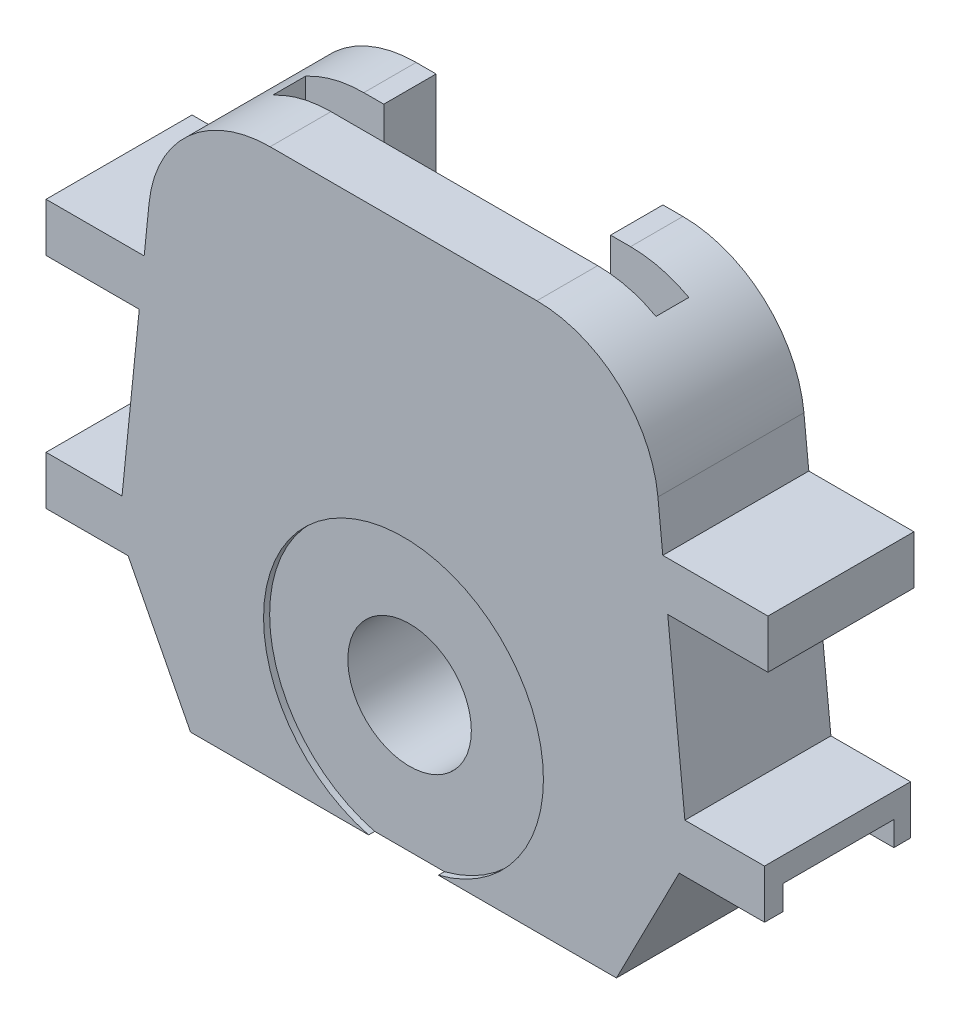
from build123d import *

# Parameters (mm, degrees)
SKETCH2_R           = 5.075
BOSS_EXTRUDE1_DEPTH = 12
CUT_EXTRUDE1_DEPTH  = 2
SKETCH4_W           = 31.5
SKETCH4_H           = 26.5
CUT_EXTRUDE2_DEPTH  = 2.7
CUT_EXTRUDE3_REACH  = 14
SKETCH5_W           = 18.640557444
SKETCH5_H           = 25
SKETCH6_R           = 11.5
CUT_EXTRUDE4_DEPTH  = 0.5


with BuildPart() as part:
    # Sketch2 → Boss-Extrude1 (new body)
    with BuildSketch(Plane.XY):
        with BuildLine():
            Line((-26.652708458, 24.799544054), (-27.052594325, 20.847218157))
            Line((-27.052594325, 20.847218157), (-35.117996865, 20.847218157))
            Line((-35.117996865, 20.847218157), (-35.117996865, 16.847218157))
            Line((-35.117996865, 16.847218157), (-27.457303732, 16.847218157))
            Line((-27.457303732, 16.847218157), (-28.873786654, 2.847218157))
            Line((-28.873786654, 2.847218157), (-35.117996865, 2.839337807))
            Line((-35.117996865, 2.839337807), (-35.112948764, -1.160662193))
            Line((-35.112948764, -1.160662193), (-28.37093921, -1.152153607))
            Line((-28.37093921, -1.152153607), (-23.24278353, -11.137592085))
            Line((-23.24278353, -11.137592085), (11.75721647, -11.137592085))
            Line((11.75721647, -11.137592085), (16.91451101, -1.09500223))
            Line((16.91451101, -1.09500223), (23.93161739, -1.086146466))
            Line((23.93161739, -1.086146466), (23.92656929, 2.913853534))
            Line((23.92656929, 2.913853534), (17.382313229, 2.905594519))
            Line((17.382313229, 2.905594519), (15.971736672, 16.847218157))
            Line((15.971736672, 16.847218157), (24.207665477, 16.847218157))
            Line((24.207665477, 16.847218157), (24.207665477, 20.847218157))
            Line((24.207665477, 20.847218157), (15.567027266, 20.847218157))
            Line((15.567027266, 20.847218157), (15.167141399, 24.799544054))
            ThreePointArc((15.167141399, 24.799544054), (11.923667067, 31.21134436), (5.217936029, 33.792909804))
            Line((5.217936029, 33.792909804), (-16.703503089, 33.792909804))
            ThreePointArc((-16.703503089, 33.792909804), (-23.409234126, 31.21134436), (-26.652708458, 24.799544054))
        make_face()
        with Locations((-5.74278353, 0)):
            Circle(SKETCH2_R, mode=Mode.SUBTRACT)
    extrude(amount=BOSS_EXTRUDE1_DEPTH)

    # Sketch3 → Cut-Extrude1 (cut)
    with BuildSketch(Plane(origin=(0.001408858, -1.116346991, 0), x_dir=(0.999999204, 0.001262024, 0), z_dir=(0.001262024, -0.999999204, 0))):
        Polygon((-35.114385586, 10.5), (-29.114385586, 10.5), (-29.114385586, 8.5), (-29.114385586, 3.523848556), (-29.114385586, 1.461924081), (-35.114385586, 1.461924081), (-35.114385586, 3.523848556), (-35.114385586, 8.5), align=None)
        Polygon((17.930227589, 10.5), (23.930227589, 10.5), (23.930227589, 8.5), (23.930227589, 3.438075525), (23.930227589, 1.376151049), (17.930227589, 1.376151049), (17.930227589, 3.438075525), (17.930227589, 8.5), align=None)
    extrude(amount=-CUT_EXTRUDE1_DEPTH, mode=Mode.SUBTRACT)

    # Sketch4 → Cut-Extrude2 (cut)
    with BuildSketch(Plane.XY.offset(7)):
        with Locations((-5.74278353, 20.542909804)):
            Rectangle(SKETCH4_W, SKETCH4_H)
    extrude(amount=-CUT_EXTRUDE2_DEPTH, mode=Mode.SUBTRACT)

    # Sketch5 → Cut-Extrude3 (cut, up to next)
    with BuildSketch(Plane(origin=(0, 0, 0), x_dir=(-1, 0, 0), z_dir=(0, 0, -1)), mode=Mode.PRIVATE) as cut_extrude3_sk1:
        with Locations((5.74278353, 21.292909804)):
            Rectangle(SKETCH5_W, SKETCH5_H)
    cut_extrude3_tool1 = extrude(cut_extrude3_sk1.sketch, amount=-CUT_EXTRUDE3_REACH, mode=Mode.PRIVATE) & part.part
    add(cut_extrude3_tool1.solids().sort_by_distance((-5.742784, 21.29291, 0))[0], mode=Mode.SUBTRACT)

    # Sketch6 → Cut-Extrude4 (cut)
    with BuildSketch(Plane.XY.offset(12)):
        with Locations((-5.74278353, 0)):
            Circle(SKETCH6_R)
    extrude(amount=-CUT_EXTRUDE4_DEPTH, mode=Mode.SUBTRACT)


solid = part.part
